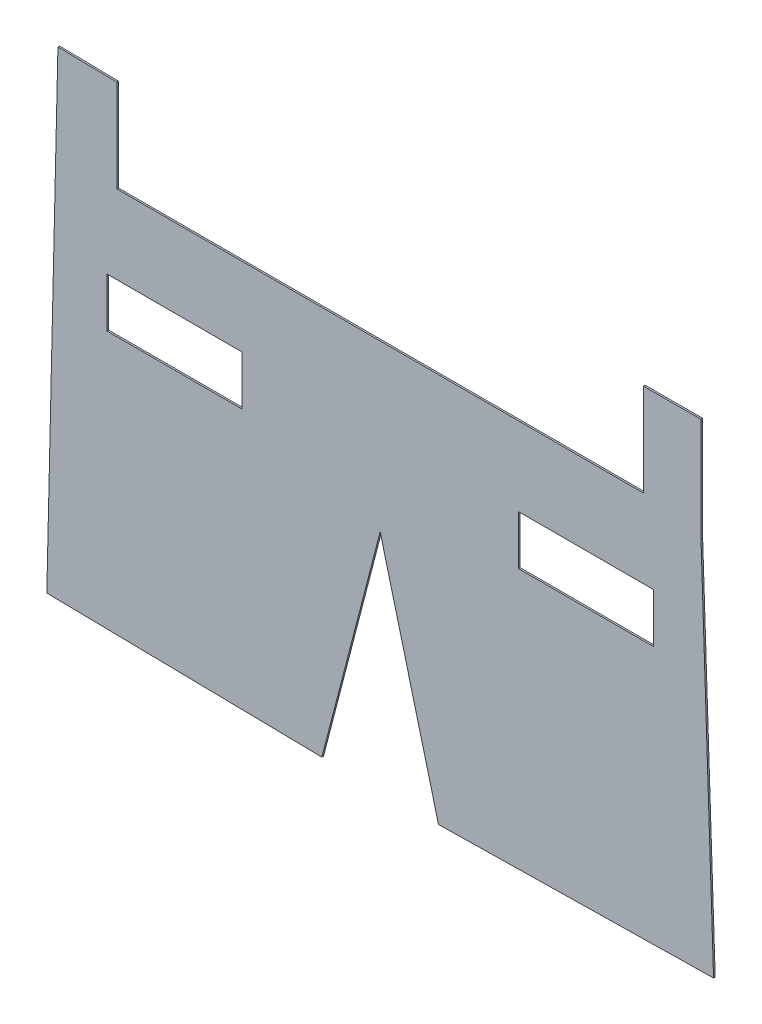
from build123d import *

# Parameters (mm, degrees)
MODEL_W                 = 8.2
MODEL_H                 = 3
SALIENTE_EXTRUIR1_DEPTH = 0.1


with BuildPart() as part:
    # Model → Saliente-Extruir1 (new body)
    with BuildSketch(Plane.XY):
        Polygon((50.124922154, 24.617645317), (50.124922154, 19.617645317), (50.887641035, -3.103510086), (34.169357615, -3.381657238), (30.626179611, 10.250358005), (27.083001606, -3.381657238), (10.364718187, -3.103510086), (11.040374185, 25.978480921), (14.626179611, 25.917645317), (14.626179611, 20.295679334), (46.626179611, 20.295679334), (46.626179611, 25.917645317), (50.124922154, 25.9284032), align=None)
        with Locations((18.126179611, 14.017645317)):
            Rectangle(MODEL_W, MODEL_H, mode=Mode.SUBTRACT)
        with Locations((43.126179611, 14.017645317)):
            Rectangle(MODEL_W, MODEL_H, mode=Mode.SUBTRACT)
    extrude(amount=SALIENTE_EXTRUIR1_DEPTH)


solid = part.part
